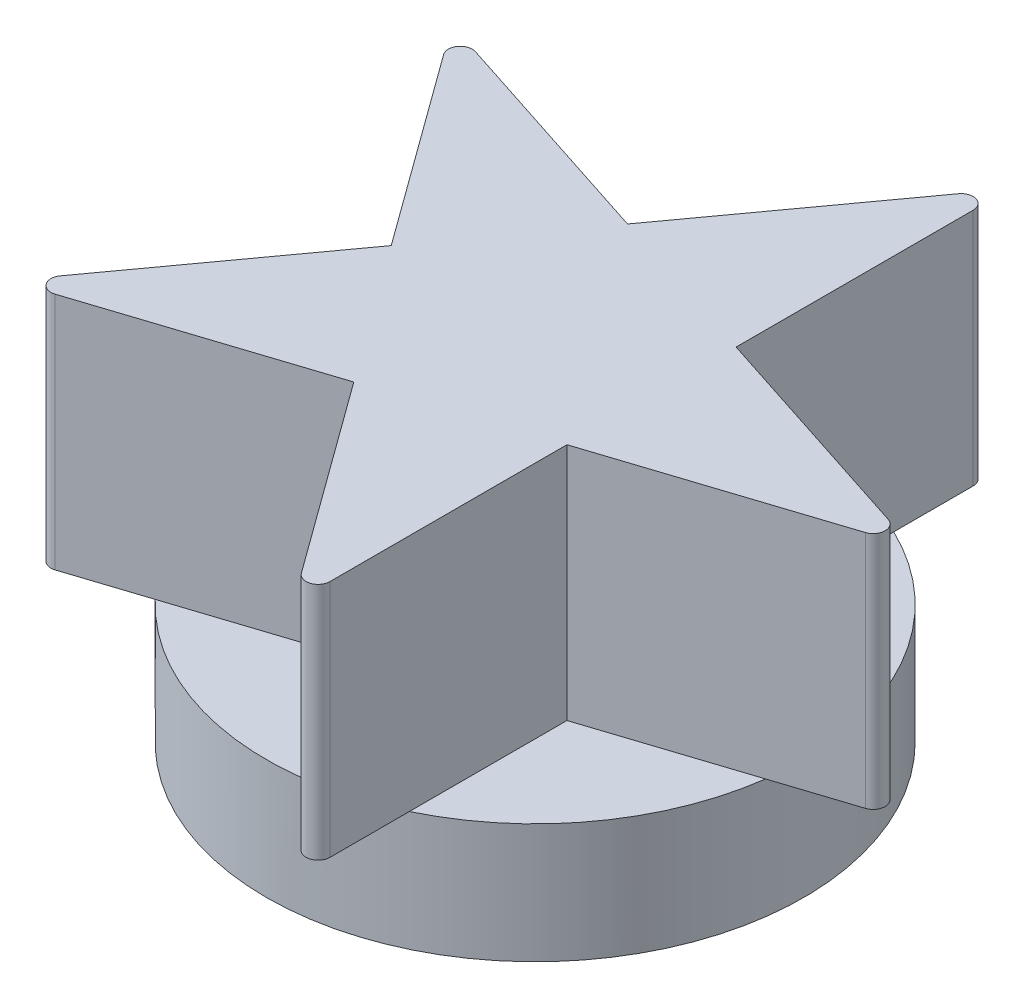
from build123d import *

# Parameters (mm, degrees)
SKETCH1_R           = 22.5
BOSS_EXTRUDE1_DEPTH = 10
BOSS_EXTRUDE2_DEPTH = 20
SKETCH3_R           = 16.5
CUT_EXTRUDE2_DEPTH  = 5


with BuildPart() as part:
    # Sketch1 → Boss-Extrude1 (new body)
    with BuildSketch(Plane(origin=(0, 0, 0), x_dir=(1, 0, 0), z_dir=(0, 1, 0))):
        Circle(SKETCH1_R)
    extrude(amount=BOSS_EXTRUDE1_DEPTH)

    # Sketch2 → Boss-Extrude2 (add)
    with BuildSketch(Plane(origin=(0, 10, 0), x_dir=(1, 0, 0), z_dir=(0, 1, 0))):
        with BuildLine():
            Line((9.747590887, 26.922316463), (9.747590887, 7.082039325))
            Line((9.747590887, 7.082039325), (28.616815744, 0.951056516))
            ThreePointArc((28.616815744, 0.951056516), (29.30779875, 0), (28.616815744, -0.951056516))
            Line((28.616815744, -0.951056516), (9.747590887, -7.082039325))
            Line((9.747590887, -7.082039325), (9.747590887, -26.922316463))
            ThreePointArc((9.747590887, -26.922316463), (9.056607881, -27.873372979), (7.938573893, -27.510101715))
            Line((7.938573893, -27.510101715), (-3.72324841, -11.458980338))
            Line((-3.72324841, -11.458980338), (-22.592473267, -17.589963146))
            ThreePointArc((-22.592473267, -17.589963146), (-23.710507256, -17.226691882), (-23.710507256, -16.051121378))
            Line((-23.710507256, -16.051121378), (-12.048684953, 0))
            Line((-12.048684953, 0), (-23.710507256, 16.051121378))
            ThreePointArc((-23.710507256, 16.051121378), (-23.710507256, 17.226691882), (-22.592473267, 17.589963146))
            Line((-22.592473267, 17.589963146), (-3.72324841, 11.458980338))
            Line((-3.72324841, 11.458980338), (7.938573893, 27.510101715))
            ThreePointArc((7.938573893, 27.510101715), (9.056607881, 27.873372979), (9.747590887, 26.922316463))
        make_face()
    extrude(amount=BOSS_EXTRUDE2_DEPTH)

    # Sketch3 → Cut-Extrude2 (cut)
    with BuildSketch(Plane.XZ):
        with BuildLine():
            ThreePointArc((-14.551420086, 2.778571429), (0, 11.5), (14.551420086, 2.778571429))
            Line((14.551420086, 2.778571429), (4.83856504, 20.948467447))
            ThreePointArc((4.83856504, 20.948467447), (0, 21.5), (-4.83856504, 20.948467447))
            Line((-4.83856504, 20.948467447), (-14.551420086, 2.778571429))
        make_face()
        with Locations((0, -5)):
            Circle(SKETCH3_R)
    extrude(amount=-CUT_EXTRUDE2_DEPTH, mode=Mode.SUBTRACT)


solid = part.part
